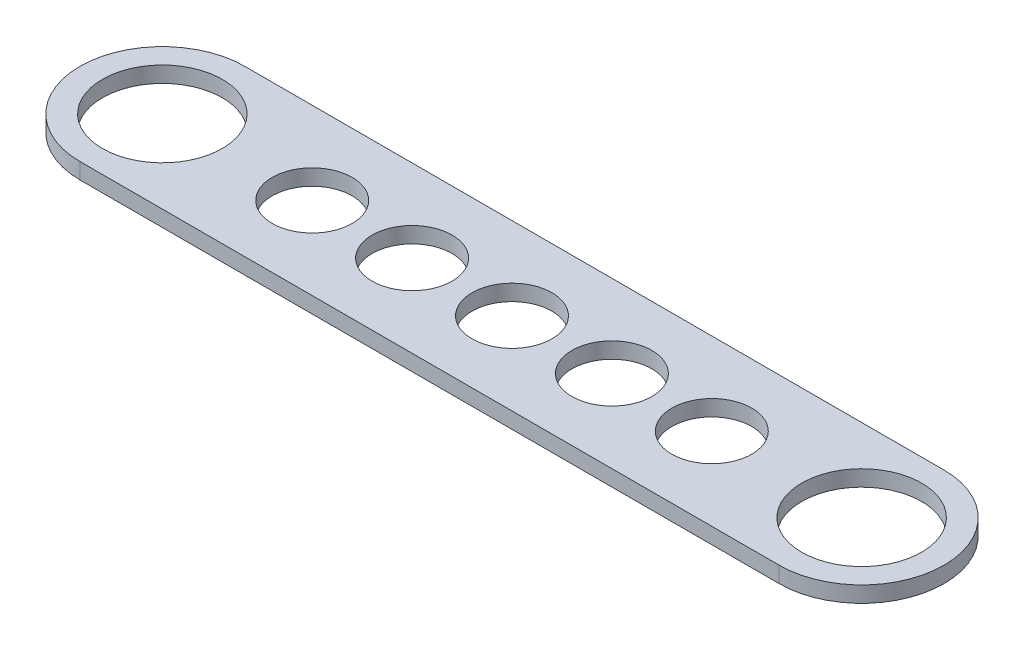
from build123d import *

# Parameters (mm, degrees)
SKETCH1_R           = 15.24
BOSS_EXTRUDE1_DEPTH = 4.064
SKETCH2_R           = 10.16
CUT_EXTRUDE1_DEPTH  = 5.064
LPATTERN1_COUNT     = 5
LPATTERN1_PITCH     = 25.4


with BuildPart() as part:
    # Sketch1 → Boss-Extrude1 (new body)
    with BuildSketch(Plane(origin=(0, 0, 0), x_dir=(1, 0, 0), z_dir=(0, 1, 0))):
        with BuildLine():
            Line((0, 20.955), (177.8, 20.955))
            ThreePointArc((177.8, 20.955), (198.755, 0), (177.8, -20.955))
            Line((177.8, -20.955), (0, -20.955))
            ThreePointArc((0, -20.955), (-20.955, 0), (0, 20.955))
        make_face()
        Circle(SKETCH1_R, mode=Mode.SUBTRACT)
        with Locations((177.8, 0)):
            Circle(SKETCH1_R, mode=Mode.SUBTRACT)
    extrude(amount=BOSS_EXTRUDE1_DEPTH)

    # Sketch2 → Cut-Extrude1 (cut, through all)
    with BuildSketch(Plane(origin=(0, 4.064, 0), x_dir=(1, 0, 0), z_dir=(0, 1, 0))):
        with Locations((38.1, 0)):
            Circle(SKETCH2_R)
    cut_extrude1 = extrude(amount=-CUT_EXTRUDE1_DEPTH, mode=Mode.SUBTRACT)

    # LPattern1: Cut-Extrude1 ×5
    with Locations(*[(i * LPATTERN1_PITCH, 0, 0) for i in range(1, LPATTERN1_COUNT)]):
        add(cut_extrude1, mode=Mode.SUBTRACT)


solid = part.part
